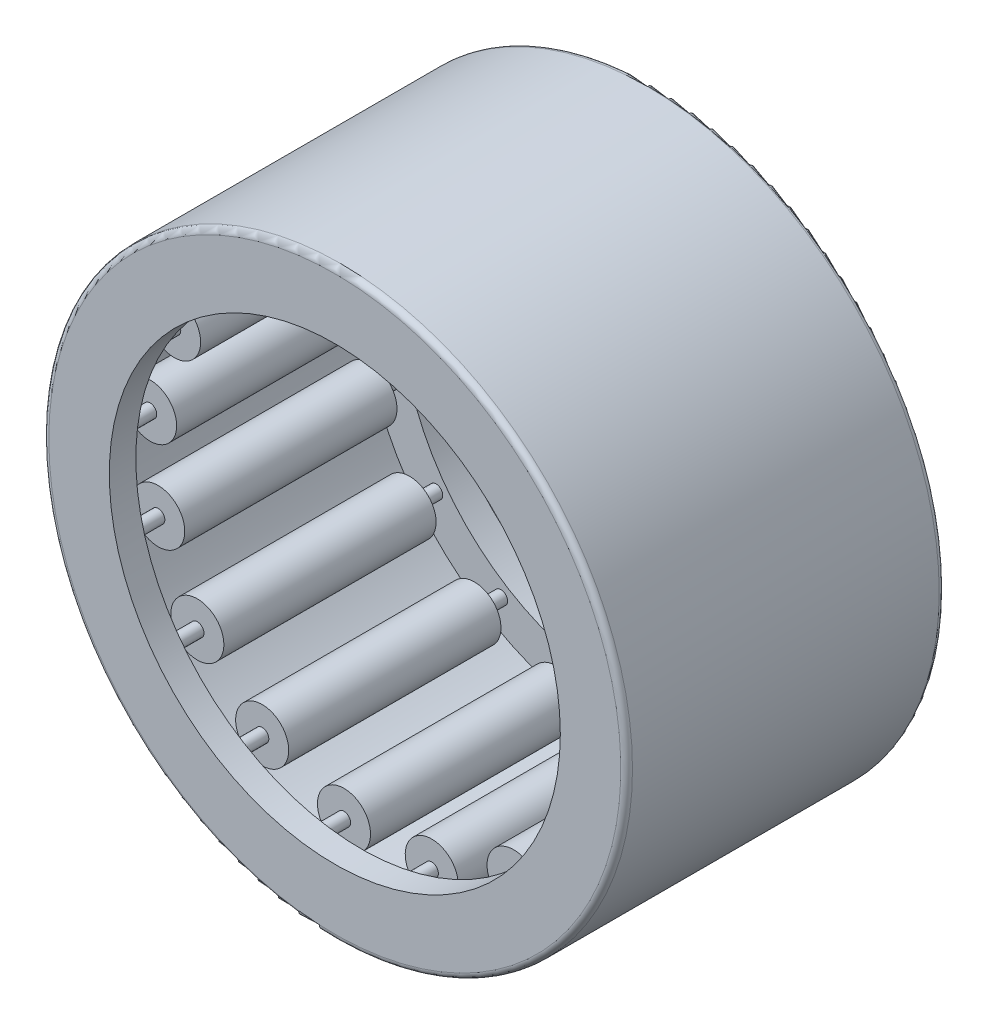
from build123d import *

# Parameters (mm, degrees)
SKETCH2_W         = 8
SKETCH2_H         = 0.75
SKETCH3_W         = 10
SKETCH3_H         = 0.25
CIRPATTERN1_COUNT = 17
CIRPATTERN1_ANGLE = 338.823529412
FILLET1_R         = 0.22


with BuildPart() as part:
    # Sketch1 → Revolve1 (revolve)
    with BuildSketch(Plane(origin=(0, 0, 0), x_dir=(0, 0, -1), z_dir=(1, 0, 0))):
        Polygon((-6, 11), (6, 11), (6, 8.5), (5, 8.5), (5, 10), (-5, 10), (-5, 8.5), (-6, 8.5), align=None)
    revolve(axis=Axis((0, 0, 6), (0, 0, -1)))

    # Fillet1
    fillet1_edges = [part.edges().sort_by_distance(p)[0] for p in [
        (0, -11, 6),
        (0, -11, -6),
    ]]
    fillet(fillet1_edges, radius=FILLET1_R)


with BuildPart() as body_2:
    # Sketch2 → Revolve2 (revolve)
    with BuildSketch(Plane(origin=(0, 0, 0), x_dir=(0, 0, -1), z_dir=(1, 0, 0))):
        with Locations((0, 9.625)):
            Rectangle(SKETCH2_W, SKETCH2_H)
    revolve(axis=Axis((0, 9, 4), (0, 0, -1)))


with BuildPart() as body_3:
    # Sketch3 → Revolve3 (revolve)
    with BuildSketch(Plane(origin=(0, 0, 0), x_dir=(0, 0, -1), z_dir=(1, 0, 0))):
        with Locations((0, 9.125)):
            Rectangle(SKETCH3_W, SKETCH3_H)
    revolve(axis=Axis((0, 9, 5), (0, 0, -1)))


with BuildPart() as cirpattern1_1:
    # CirPattern1: pattern copy
    add(body_2.part.rotate(Axis((0, 0, -6), (0, 0, 1)), 1 * CIRPATTERN1_ANGLE / (CIRPATTERN1_COUNT - 1)))


with BuildPart() as cirpattern1_2:
    # CirPattern1: pattern copy
    add(body_2.part.rotate(Axis((0, 0, -6), (0, 0, 1)), 2 * CIRPATTERN1_ANGLE / (CIRPATTERN1_COUNT - 1)))


with BuildPart() as cirpattern1_3:
    # CirPattern1: pattern copy
    add(body_2.part.rotate(Axis((0, 0, -6), (0, 0, 1)), 3 * CIRPATTERN1_ANGLE / (CIRPATTERN1_COUNT - 1)))


with BuildPart() as cirpattern1_4:
    # CirPattern1: pattern copy
    add(body_2.part.rotate(Axis((0, 0, -6), (0, 0, 1)), 4 * CIRPATTERN1_ANGLE / (CIRPATTERN1_COUNT - 1)))


with BuildPart() as cirpattern1_5:
    # CirPattern1: pattern copy
    add(body_2.part.rotate(Axis((0, 0, -6), (0, 0, 1)), 5 * CIRPATTERN1_ANGLE / (CIRPATTERN1_COUNT - 1)))


with BuildPart() as cirpattern1_6:
    # CirPattern1: pattern copy
    add(body_2.part.rotate(Axis((0, 0, -6), (0, 0, 1)), 6 * CIRPATTERN1_ANGLE / (CIRPATTERN1_COUNT - 1)))


with BuildPart() as cirpattern1_7:
    # CirPattern1: pattern copy
    add(body_2.part.rotate(Axis((0, 0, -6), (0, 0, 1)), 7 * CIRPATTERN1_ANGLE / (CIRPATTERN1_COUNT - 1)))


with BuildPart() as cirpattern1_8:
    # CirPattern1: pattern copy
    add(body_2.part.rotate(Axis((0, 0, -6), (0, 0, 1)), 8 * CIRPATTERN1_ANGLE / (CIRPATTERN1_COUNT - 1)))


with BuildPart() as cirpattern1_9:
    # CirPattern1: pattern copy
    add(body_2.part.rotate(Axis((0, 0, -6), (0, 0, 1)), 9 * CIRPATTERN1_ANGLE / (CIRPATTERN1_COUNT - 1)))


with BuildPart() as cirpattern1_10:
    # CirPattern1: pattern copy
    add(body_2.part.rotate(Axis((0, 0, -6), (0, 0, 1)), 10 * CIRPATTERN1_ANGLE / (CIRPATTERN1_COUNT - 1)))


with BuildPart() as cirpattern1_11:
    # CirPattern1: pattern copy
    add(body_2.part.rotate(Axis((0, 0, -6), (0, 0, 1)), 11 * CIRPATTERN1_ANGLE / (CIRPATTERN1_COUNT - 1)))


with BuildPart() as cirpattern1_12:
    # CirPattern1: pattern copy
    add(body_2.part.rotate(Axis((0, 0, -6), (0, 0, 1)), 12 * CIRPATTERN1_ANGLE / (CIRPATTERN1_COUNT - 1)))


with BuildPart() as cirpattern1_13:
    # CirPattern1: pattern copy
    add(body_2.part.rotate(Axis((0, 0, -6), (0, 0, 1)), 13 * CIRPATTERN1_ANGLE / (CIRPATTERN1_COUNT - 1)))


with BuildPart() as cirpattern1_14:
    # CirPattern1: pattern copy
    add(body_2.part.rotate(Axis((0, 0, -6), (0, 0, 1)), 14 * CIRPATTERN1_ANGLE / (CIRPATTERN1_COUNT - 1)))


with BuildPart() as cirpattern1_15:
    # CirPattern1: pattern copy
    add(body_2.part.rotate(Axis((0, 0, -6), (0, 0, 1)), 15 * CIRPATTERN1_ANGLE / (CIRPATTERN1_COUNT - 1)))


with BuildPart() as cirpattern1_16:
    # CirPattern1: pattern copy
    add(body_2.part.rotate(Axis((0, 0, -6), (0, 0, 1)), 16 * CIRPATTERN1_ANGLE / (CIRPATTERN1_COUNT - 1)))


with BuildPart() as cirpattern1_17:
    # CirPattern1: pattern copy
    add(body_3.part.rotate(Axis((0, 0, -6), (0, 0, 1)), 1 * CIRPATTERN1_ANGLE / (CIRPATTERN1_COUNT - 1)))


with BuildPart() as cirpattern1_18:
    # CirPattern1: pattern copy
    add(body_3.part.rotate(Axis((0, 0, -6), (0, 0, 1)), 2 * CIRPATTERN1_ANGLE / (CIRPATTERN1_COUNT - 1)))


with BuildPart() as cirpattern1_19:
    # CirPattern1: pattern copy
    add(body_3.part.rotate(Axis((0, 0, -6), (0, 0, 1)), 3 * CIRPATTERN1_ANGLE / (CIRPATTERN1_COUNT - 1)))


with BuildPart() as cirpattern1_20:
    # CirPattern1: pattern copy
    add(body_3.part.rotate(Axis((0, 0, -6), (0, 0, 1)), 4 * CIRPATTERN1_ANGLE / (CIRPATTERN1_COUNT - 1)))


with BuildPart() as cirpattern1_21:
    # CirPattern1: pattern copy
    add(body_3.part.rotate(Axis((0, 0, -6), (0, 0, 1)), 5 * CIRPATTERN1_ANGLE / (CIRPATTERN1_COUNT - 1)))


with BuildPart() as cirpattern1_22:
    # CirPattern1: pattern copy
    add(body_3.part.rotate(Axis((0, 0, -6), (0, 0, 1)), 6 * CIRPATTERN1_ANGLE / (CIRPATTERN1_COUNT - 1)))


with BuildPart() as cirpattern1_23:
    # CirPattern1: pattern copy
    add(body_3.part.rotate(Axis((0, 0, -6), (0, 0, 1)), 7 * CIRPATTERN1_ANGLE / (CIRPATTERN1_COUNT - 1)))


with BuildPart() as cirpattern1_24:
    # CirPattern1: pattern copy
    add(body_3.part.rotate(Axis((0, 0, -6), (0, 0, 1)), 8 * CIRPATTERN1_ANGLE / (CIRPATTERN1_COUNT - 1)))


with BuildPart() as cirpattern1_25:
    # CirPattern1: pattern copy
    add(body_3.part.rotate(Axis((0, 0, -6), (0, 0, 1)), 9 * CIRPATTERN1_ANGLE / (CIRPATTERN1_COUNT - 1)))


with BuildPart() as cirpattern1_26:
    # CirPattern1: pattern copy
    add(body_3.part.rotate(Axis((0, 0, -6), (0, 0, 1)), 10 * CIRPATTERN1_ANGLE / (CIRPATTERN1_COUNT - 1)))


with BuildPart() as cirpattern1_27:
    # CirPattern1: pattern copy
    add(body_3.part.rotate(Axis((0, 0, -6), (0, 0, 1)), 11 * CIRPATTERN1_ANGLE / (CIRPATTERN1_COUNT - 1)))


with BuildPart() as cirpattern1_28:
    # CirPattern1: pattern copy
    add(body_3.part.rotate(Axis((0, 0, -6), (0, 0, 1)), 12 * CIRPATTERN1_ANGLE / (CIRPATTERN1_COUNT - 1)))


with BuildPart() as cirpattern1_29:
    # CirPattern1: pattern copy
    add(body_3.part.rotate(Axis((0, 0, -6), (0, 0, 1)), 13 * CIRPATTERN1_ANGLE / (CIRPATTERN1_COUNT - 1)))


with BuildPart() as cirpattern1_30:
    # CirPattern1: pattern copy
    add(body_3.part.rotate(Axis((0, 0, -6), (0, 0, 1)), 14 * CIRPATTERN1_ANGLE / (CIRPATTERN1_COUNT - 1)))


with BuildPart() as cirpattern1_31:
    # CirPattern1: pattern copy
    add(body_3.part.rotate(Axis((0, 0, -6), (0, 0, 1)), 15 * CIRPATTERN1_ANGLE / (CIRPATTERN1_COUNT - 1)))


with BuildPart() as cirpattern1_32:
    # CirPattern1: pattern copy
    add(body_3.part.rotate(Axis((0, 0, -6), (0, 0, 1)), 16 * CIRPATTERN1_ANGLE / (CIRPATTERN1_COUNT - 1)))


solid = Compound([part.part, body_2.part, body_3.part, cirpattern1_1.part, cirpattern1_2.part, cirpattern1_3.part, cirpattern1_4.part, cirpattern1_5.part, cirpattern1_6.part, cirpattern1_7.part, cirpattern1_8.part, cirpattern1_9.part, cirpattern1_10.part, cirpattern1_11.part, cirpattern1_12.part, cirpattern1_13.part, cirpattern1_14.part, cirpattern1_15.part, cirpattern1_16.part, cirpattern1_17.part, cirpattern1_18.part, cirpattern1_19.part, cirpattern1_20.part, cirpattern1_21.part, cirpattern1_22.part, cirpattern1_23.part, cirpattern1_24.part, cirpattern1_25.part, cirpattern1_26.part, cirpattern1_27.part, cirpattern1_28.part, cirpattern1_29.part, cirpattern1_30.part, cirpattern1_31.part, cirpattern1_32.part])
